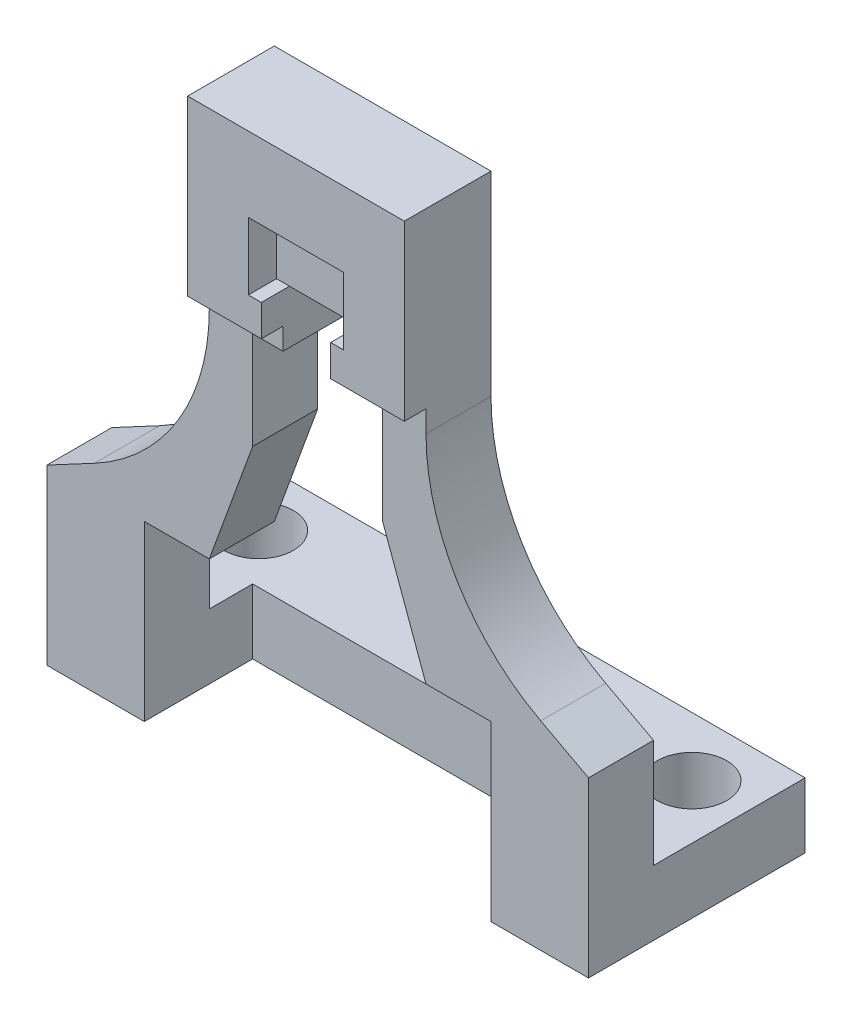
from build123d import *

# Parameters (mm, degrees)
SKETCH7_W               = 25
SKETCH7_H               = 10
SKETCH7_R               = 1.6
BOSS_EXTRUDE3_DEPTH     = 3
SKETCH8_W               = 25
SKETCH8_H               = 3
BOSS_EXTRUDE4_DEPTH     = 24
CUT_EXTRUDE5_DEPTH      = 5
SKETCH10_OUTSIDE_W      = 34.626
SKETCH10_OUTSIDE_H      = 36.626
CUT_EXTRUDE6_DEPTH      = 5
SKETCH11_W              = 10
SKETCH11_H              = 8
BOSS_EXTRUDE5_DEPTH     = 1
CHAMFER1_SIZE           = 2
CHAMFER1_SIZE2          = 5.494954839
CHAMFER1_PART_2_SIZE    = 2
CHAMFER1_PART_2_SIZE2   = 5.494954839
CUT_EXTRUDE7_DEPTH      = 1.3
SKETCH14_W              = 3.2
SKETCH14_H              = 3.813108433
CUT_EXTRUDE9_DEPTH      = 2.3
CUT_EXTRUDE9_DEPTH_BACK = 10.7
FILLET3_R               = 10


with BuildPart() as part:
    # Sketch7 → Boss-Extrude3 (new body)
    with BuildSketch(Plane(origin=(0, 0, 0), x_dir=(1, 0, 0), z_dir=(0, 1, 0))):
        Rectangle(SKETCH7_W, SKETCH7_H)
        with Locations(Location((-10, 2.276747262, 0), (0, 0, 270))):  # turned: the seam where the file's is
            Circle(SKETCH7_R, mode=Mode.SUBTRACT)
        with Locations(Location((10, 2.276747262, 0), (0, 0, 270))):  # turned: the seam where the file's is
            Circle(SKETCH7_R, mode=Mode.SUBTRACT)
    extrude(amount=BOSS_EXTRUDE3_DEPTH)

    # Sketch8 → Boss-Extrude4 (add)
    with BuildSketch(Plane(origin=(0, 3, 0), x_dir=(1, 0, 0), z_dir=(0, 1, 0))):
        with Locations((0, -3.5)):
            Rectangle(SKETCH8_W, SKETCH8_H)
    extrude(amount=BOSS_EXTRUDE4_DEPTH)

    # Sketch9 → Cut-Extrude5 (cut)
    with BuildSketch(Plane.XY.offset(5)):
        Polygon((8, 8), (8, 0), (-8, 0), (-8, 8), (-3, 8), (-3, 18), (3, 18), (3, 8), align=None)
    extrude(amount=-CUT_EXTRUDE5_DEPTH, mode=Mode.SUBTRACT)

    # Sketch10 outside → Cut-Extrude6 (cut)
    with BuildSketch(Plane.XY.offset(5)):
        with Locations((0, 13.5)):
            Rectangle(SKETCH10_OUTSIDE_W, SKETCH10_OUTSIDE_H)
        Polygon((-5, 27), (-5, 12), (-12.5, 8), (-12.5, 0), (12.5, 0), (12.5, 8), (5, 12), (5, 27), align=None, mode=Mode.SUBTRACT)
    extrude(amount=-CUT_EXTRUDE6_DEPTH, mode=Mode.SUBTRACT)

    # Sketch11 → Boss-Extrude5 (add)
    with BuildSketch(Plane.XY.offset(5)):
        with Locations((0, 23)):
            Rectangle(SKETCH11_W, SKETCH11_H)
    extrude(amount=BOSS_EXTRUDE5_DEPTH)

    # Chamfer1
    chamfer1_edges = [part.edges().sort_by_distance(p)[0] for p in [
        (-3, 8, 3.5),
    ]]
    chamfer1_side = [part.faces().sort_by_distance(p)[0] for p in [
        (-5.5, 8, 3.5),
    ]]
    chamfer(chamfer1_edges, length=CHAMFER1_SIZE, length2=CHAMFER1_SIZE2, reference=chamfer1_side[0])

    # Chamfer1 part 2
    chamfer1_part_2_edges = [part.edges().sort_by_distance(p)[0] for p in [
        (3, 8, 3.5),
    ]]
    chamfer1_part_2_side = [part.faces().sort_by_distance(p)[0] for p in [
        (5.5, 8, 3.5),
    ]]
    chamfer(chamfer1_part_2_edges, length=CHAMFER1_PART_2_SIZE, length2=CHAMFER1_PART_2_SIZE2, reference=chamfer1_part_2_side[0])

    # Sketch12 → Cut-Extrude7 (cut)
    with BuildSketch(Plane.XY.offset(6)):
        Polygon((-2.2, 20.45), (-1.6, 20.45), (-1.6, 19), (1.6, 19), (1.6, 20.45), (2.2, 20.45), (2.2, 23.55), (-2.2, 23.55), align=None)
    extrude(amount=-CUT_EXTRUDE7_DEPTH, mode=Mode.SUBTRACT)

    # Sketch14 → Cut-Extrude9 (cut, two sides)
    with BuildSketch(Plane.XY.offset(4.7)) as cut_extrude9_sk:
        with Locations((0, 18.543445784)):
            Rectangle(SKETCH14_W, SKETCH14_H)
    extrude(amount=CUT_EXTRUDE9_DEPTH, mode=Mode.SUBTRACT)
    extrude(cut_extrude9_sk.sketch, amount=-CUT_EXTRUDE9_DEPTH_BACK, mode=Mode.SUBTRACT)

    # Fillet3
    fillet3_edges = [part.edges().sort_by_distance(p)[0] for p in [
        (-5, 12, 3.5),
        (5, 12, 3.5),
    ]]
    fillet(fillet3_edges, radius=FILLET3_R)


solid = part.part
